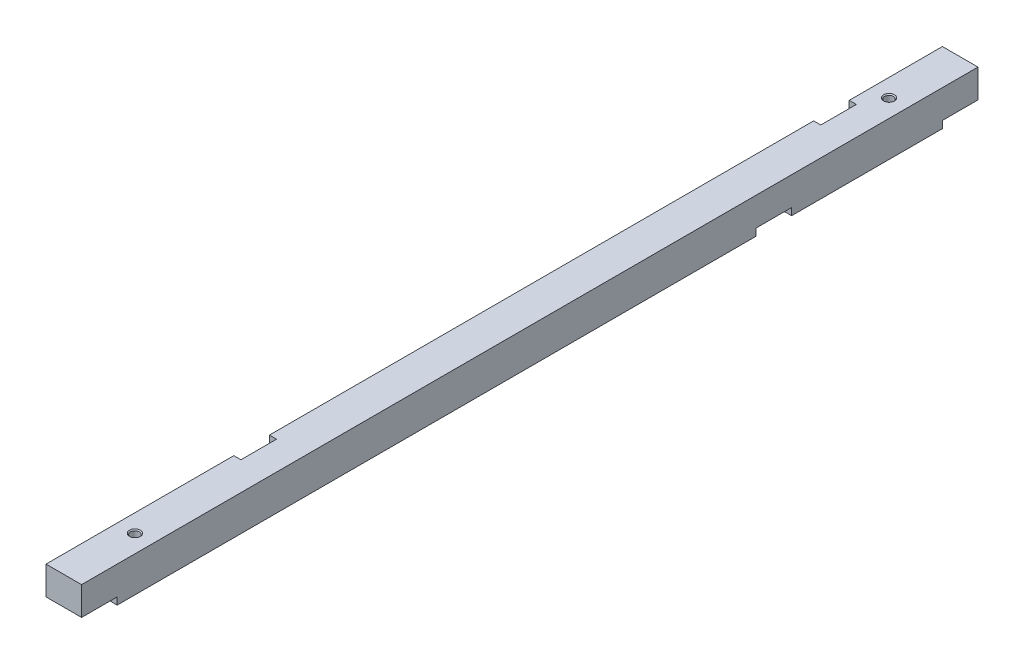
from build123d import *

# Parameters (mm, degrees)
ESQUISSE1_W                     = 10
ESQUISSE1_H                     = 10
BOSS_EXTRU_1_DEPTH              = 252
ESQUISSE2_W                     = 10
ESQUISSE2_H                     = 2
ENL_V_MAT_EXTRU_1_DEPTH         = 11
ESQUISSE5_W                     = 2
ESQUISSE5_H                     = 10
ENL_V_MAT_EXTRU_4_DEPTH         = 11
TROU_TARAUD_M3X0_51_D           = 2.5
TROU_TARAUD_M3X0_51_CSINK_D     = 3.05
TROU_TARAUD_M3X0_51_CSINK_ANGLE = 90


with BuildPart() as part:
    # Esquisse1 → Boss.-Extru.1 (new body)
    with BuildSketch(Plane.XY):
        Rectangle(ESQUISSE1_W, ESQUISSE1_H)
    extrude(amount=BOSS_EXTRU_1_DEPTH)

    # Esquisse2 → Enlèv. mat.-Extru.1 (cut, through all)
    with BuildSketch(Plane.ZY.offset(5)):
        with Locations((5, -4)):
            Rectangle(ESQUISSE2_W, ESQUISSE2_H)
        with Locations((57.4, -4)):
            Rectangle(ESQUISSE2_W, ESQUISSE2_H)
        with Locations((247, -4)):
            Rectangle(ESQUISSE2_W, ESQUISSE2_H)
    extrude(amount=-ENL_V_MAT_EXTRU_1_DEPTH, mode=Mode.SUBTRACT)

    # Esquisse5 → Enlèv. mat.-Extru.4 (cut, through all)
    with BuildSketch(Plane(origin=(0, 5, 0), x_dir=(1, 0, 0), z_dir=(0, 1, 0))):
        with Locations((-4, -194.2)):
            Rectangle(ESQUISSE5_W, ESQUISSE5_H)
        with Locations((-4, -31.2)):
            Rectangle(ESQUISSE5_W, ESQUISSE5_H)
    extrude(amount=-ENL_V_MAT_EXTRU_4_DEPTH, mode=Mode.SUBTRACT)

    # Trou taraudé M3x0.51 (through all)
    with Locations(Plane(origin=(0, 5, 0), x_dir=(1, 0, 0), z_dir=(0, 1, 0))):
        with Locations((0, -20), (0, -232)):
            CounterSinkHole(TROU_TARAUD_M3X0_51_D / 2, TROU_TARAUD_M3X0_51_CSINK_D / 2, counter_sink_angle=TROU_TARAUD_M3X0_51_CSINK_ANGLE)


solid = part.part
